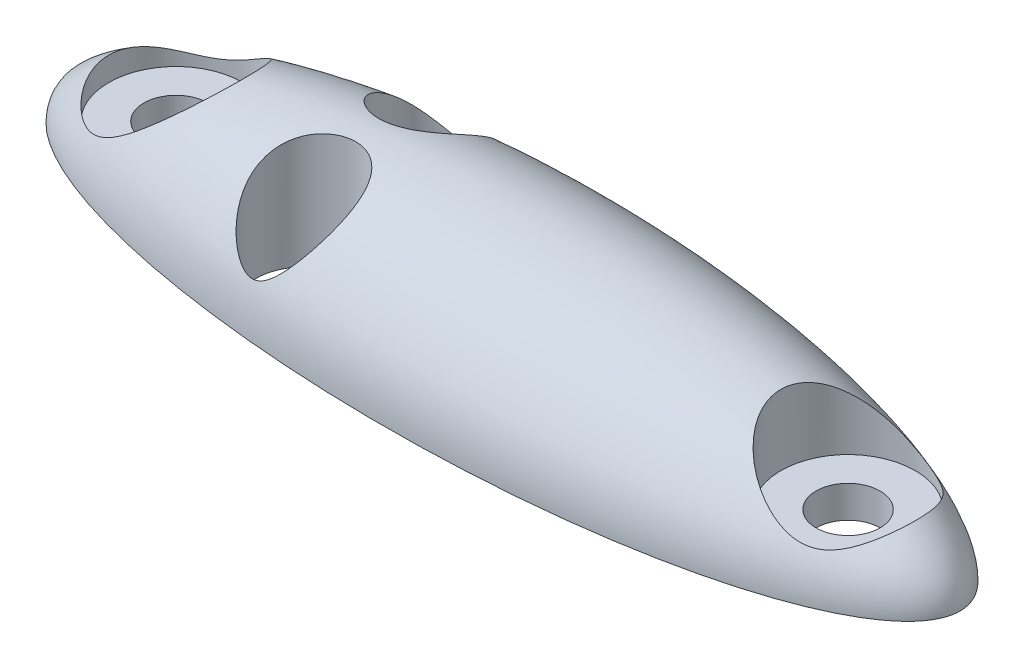
from build123d import *

# Parameters (mm, degrees)
SKETCH2_W               = 50.634745493
SKETCH2_H               = 13.07277583
CUT_EXTRUDE1_DEPTH      = 5.0000001
CUT_EXTRUDE1_DEPTH_BACK = 5.0000001
SKETCH3_R               = 1
CUT_EXTRUDE2_DEPTH      = 5.0000001
SKETCH4_R               = 2.1
CUT_EXTRUDE3_DEPTH      = 4.0000001
SKETCH5_R               = 1.5
CUT_EXTRUDE4_DEPTH      = 5.0000001


with BuildPart() as part:
    # Sketch1 → Revolve1 (revolve)
    with BuildSketch(Plane.XY):
        with BuildLine():
            Line((-14, 0), (14, 0))
            add(Edge.make_bspline(
                [(14, 0), (14, 4), (0, 4), (-14, 4), (-14, 0)],
                knots=[0, 0, 0, 1.570796327, 1.570796327, 3.141592654, 3.141592654, 3.141592654], degree=2, weights=[1, 0.707106781, 1, 0.707106781, 1]))
        make_face()
    revolve(axis=Axis((-14, 0, 0), (1, 0, 0)))

    # Sketch2 → Cut-Extrude1 (cut, two sides)
    with BuildSketch(Plane.XY) as cut_extrude1_sk:
        with Locations((-1.598405816, -6.536387915)):
            Rectangle(SKETCH2_W, SKETCH2_H)
    extrude(amount=CUT_EXTRUDE1_DEPTH, mode=Mode.SUBTRACT)
    extrude(cut_extrude1_sk.sketch, amount=-CUT_EXTRUDE1_DEPTH_BACK, mode=Mode.SUBTRACT)

    # Sketch3 → Cut-Extrude2 (cut, through all)
    with BuildSketch(Plane.XZ):
        with Locations((-10.5, 0)):
            Circle(SKETCH3_R)
        with Locations((10.5, 0)):
            Circle(SKETCH3_R)
    extrude(amount=-CUT_EXTRUDE2_DEPTH, mode=Mode.SUBTRACT)

    # Sketch4 → Cut-Extrude3 (cut, through all)
    with BuildSketch(Plane(origin=(0, 1, 0), x_dir=(-1, 0, 0), z_dir=(0, -1, 0))):
        with Locations((10.5, 0)):
            Circle(SKETCH4_R)
        with Locations((-10.5, 0)):
            Circle(SKETCH4_R)
    extrude(amount=-CUT_EXTRUDE3_DEPTH, mode=Mode.SUBTRACT)

    # Sketch5 → Cut-Extrude4 (cut, through all)
    with BuildSketch(Plane.XZ):
        with Locations((-4.5, 2)):
            Circle(SKETCH5_R)
        with Locations((-4.5, -2)):
            Circle(SKETCH5_R)
    extrude(amount=-CUT_EXTRUDE4_DEPTH, mode=Mode.SUBTRACT)


solid = part.part
